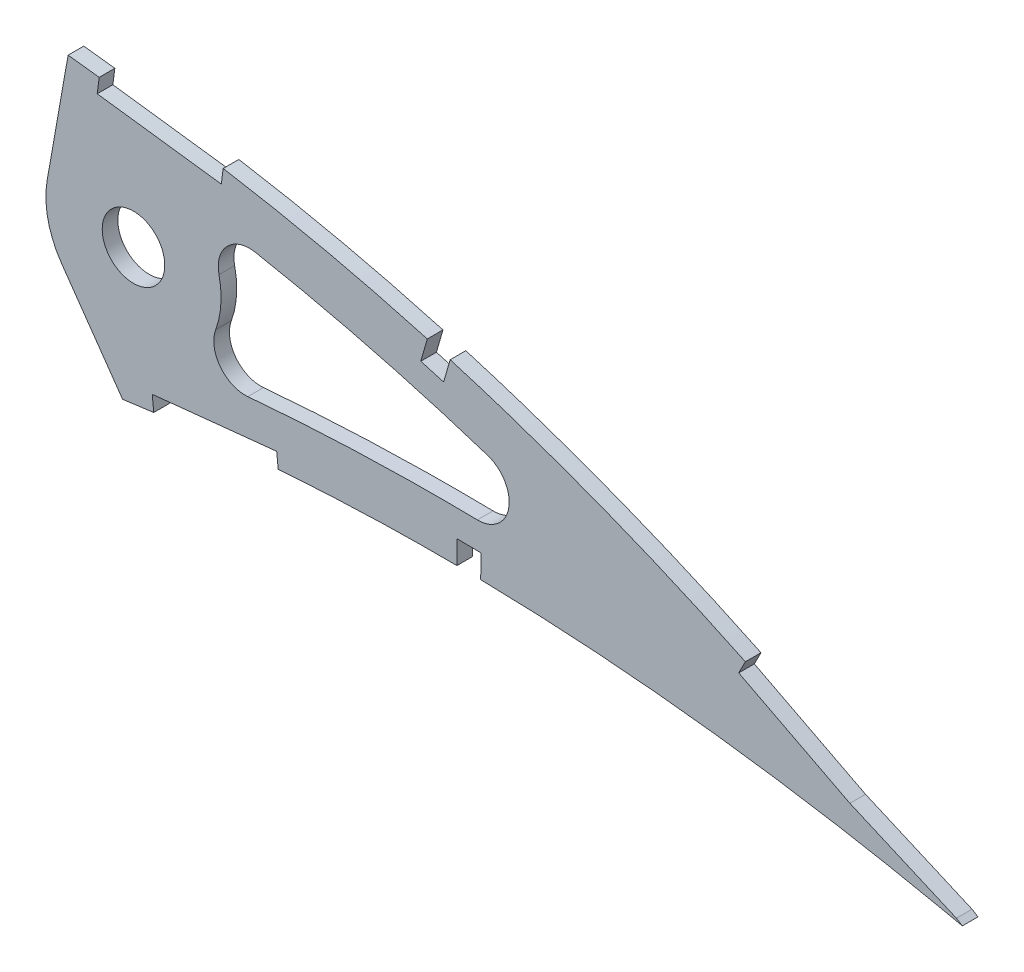
from build123d import *

# Parameters (mm, degrees)
BOSS_EXTRUDE1_DEPTH = 3.175
CUT_EXTRUDE2_DEPTH  = 547.283591975
CUT_EXTRUDE3_DEPTH  = 7.62
FILLET1_R           = 6.35


with BuildPart() as part:
    # Sketch1 → Boss-Extrude1 (new body)
    with BuildSketch(Plane.XY):
        with BuildLine():
            Line((537.523793479, 0.838014197), (542.021387547, -1.940403701))
            Line((542.021387547, -1.940403701), (536.853382121, -0.838014197))
            add(Edge.make_bspline(
                [(0, 0), (0.138034208, -0.651613517), (0.414737006, -1.957835249), (1.166502385, -3.838253351), (2.160676214, -5.645879833), (3.41812392, -7.375913216), (4.930484677, -9.027880677), (6.694418268, -10.603500449), (8.708194811, -12.101925363), (10.969178631, -13.522473474), (13.474085311, -14.866652746), (16.220099339, -16.13362747), (19.204716902, -17.323001708), (22.424686182, -18.433185568), (25.876070677, -19.465869836), (29.555588987, -20.418537931), (33.459057132, -21.292521383), (37.582720715, -22.085589251), (41.922086221, -22.79854726), (46.47264566, -23.430996401), (51.229728203, -23.983332235), (56.188666796, -24.454395789), (61.344556547, -24.845200266), (66.692258515, -25.156004942), (72.226581781, -25.387795347), (77.942225046, -25.539690341), (83.833590491, -25.614057961), (89.895353971, -25.612014663), (96.121585635, -25.533013935), (102.506966812, -25.38142005), (109.045370018, -25.156272786), (115.730892393, -24.860296695), (122.557503504, -24.496470357), (129.519080627, -24.066027182), (136.609497338, -23.570874854), (143.822597201, -23.014984243), (151.151827785, -22.399741923), (158.590797026, -21.728733991), (166.132919157, -21.00531964), (173.771677913, -20.231788358), (181.500330731, -19.411778876), (189.311993833, -18.547948429), (197.200021897, -17.644905548), (205.157209236, -16.704284062), (213.176827191, -15.731454523), (221.251331322, -14.728275603), (229.373969711, -13.698611248), (237.537436822, -12.64730964), (245.734090261, -11.574250863), (253.957036061, -10.487080023), (262.198344279, -9.384901746), (270.450841426, -8.273384527), (278.706888239, -7.155983301), (286.958443262, -6.033041983), (295.198253093, -4.90921431), (303.41867388, -3.787585418), (311.611653564, -2.668257785), (319.769779667, -1.556794947), (327.884837197, -0.453060986), (335.949343265, 0.640706274), (343.955569803, 1.721242065), (351.895963319, 2.787182649), (359.762332786, 3.837853602), (367.54676401, 4.873649521), (375.124885566, 5.86313137), (382.476895799, 6.858989414), (389.627569535, 7.675372288), (396.689208318, 8.372184453), (403.669147402, 8.943474279), (410.559005462, 9.397460881), (417.35088821, 9.737388222), (424.036701118, 9.968002084), (430.607999049, 10.096143944), (437.056574293, 10.125065717), (443.373624814, 10.063990775), (449.550934642, 9.917842246), (455.579882304, 9.693180036), (461.452056886, 9.397583865), (467.159117519, 9.039111896), (472.692496198, 8.623051856), (478.044482343, 8.159116909), (483.20681867, 7.654098497), (488.171578303, 7.113766584), (492.931516981, 6.549443229), (497.479015862, 5.964843963), (501.807234808, 5.369575836), (505.909206574, 4.769671288), (509.778434754, 4.172789296), (513.408840214, 3.584624041), (516.794558715, 3.012982056), (519.930286636, 2.463204222), (522.810582624, 1.940659579), (525.431450895, 1.451941159), (527.787715212, 0.999476696), (529.876224241, 0.590722876), (531.693094624, 0.227483345), (533.235662954, -0.085124276), (534.501235327, -0.345866251), (535.487889575, -0.550462297), (536.193676878, -0.699239352), (536.617833842, -0.78776929), (536.806292235, -0.827969433), (536.853382121, -0.838014197)],
                knots=[0, 0, 0, 0, 0.003638255, 0.007293231, 0.011028136, 0.014901081, 0.018963272, 0.023258475, 0.027820626, 0.032679082, 0.03785316, 0.043361875, 0.049214679, 0.055422346, 0.061988786, 0.068918036, 0.076211157, 0.083868392, 0.091887411, 0.100265912, 0.108999867, 0.118084529, 0.127514843, 0.13728527, 0.147387917, 0.157816481, 0.168563473, 0.179619128, 0.190977373, 0.202626974, 0.214560478, 0.226767249, 0.239236417, 0.251959004, 0.264923894, 0.278119703, 0.291536035, 0.30516028, 0.318980685, 0.332985499, 0.34716279, 0.361498603, 0.375980747, 0.390597192, 0.405332593, 0.420174823, 0.435109533, 0.450124276, 0.465203068, 0.480333154, 0.495500583, 0.510689775, 0.525887334, 0.541078314, 0.556247233, 0.571381784, 0.58646604, 0.601484516, 0.616424329, 0.631269422, 0.646006524, 0.660620684, 0.675098187, 0.689422858, 0.703581825, 0.716907563, 0.730009274, 0.742952128, 0.755725558, 0.768319952, 0.780724337, 0.792926529, 0.804916041, 0.816679084, 0.828203524, 0.8394749, 0.850481359, 0.861207697, 0.871639326, 0.881763414, 0.891563605, 0.901027364, 0.910138977, 0.918883976, 0.927249278, 0.935221104, 0.942784739, 0.949928188, 0.956638464, 0.962904203, 0.968712288, 0.974054485, 0.978918432, 0.983297218, 0.987180246, 0.990560674, 0.993433357, 0.995790626, 0.997629587, 0.998945816, 0.999736592, 1, 1, 1, 1], degree=3))
            add(Edge.make_bspline(
                [(537.523793479, 0.838014197), (537.482615732, 0.863452017), (537.318064528, 0.96510459), (536.947300697, 1.192526083), (536.329901806, 1.57130801), (535.46559731, 2.098819483), (534.355058257, 2.773659514), (532.997726083, 3.59110281), (531.394448119, 4.54849361), (529.545612388, 5.641303796), (527.451408281, 6.86441657), (525.112633224, 8.21287684), (522.529490774, 9.679050377), (519.702981637, 11.256946414), (516.634075426, 12.939060426), (513.323352771, 14.717795209), (509.771999152, 16.584102922), (505.981377851, 18.529956506), (501.952179943, 20.544610393), (497.686305121, 22.619680198), (493.18517462, 24.744819484), (488.450324771, 26.908690342), (483.484475652, 29.10247161), (478.289000223, 31.312524792), (472.866859293, 33.529274563), (467.220361199, 35.74010496), (461.352849174, 37.93494721), (455.266586971, 40.099582697), (448.966124199, 42.224551766), (442.454517235, 44.29604992), (435.736422737, 46.30282705), (428.815744024, 48.23187216), (421.698250245, 50.073291993), (414.388455333, 51.81367658), (406.892554856, 53.441376499), (399.216507212, 54.946591973), (391.366750067, 56.314295462), (383.365035839, 57.543420661), (375.340110277, 58.565844722), (367.331695381, 59.568608396), (359.33520696, 60.510613179), (351.240984711, 61.412713021), (343.056815752, 62.269828969), (334.790818119, 63.079280807), (326.451359929, 63.837575043), (318.047107413, 64.542487925), (309.586192901, 65.190025104), (301.077537968, 65.77918901), (292.529554555, 66.304800113), (283.951347283, 66.766463817), (275.351624178, 67.160960307), (266.739334656, 67.485571411), (258.123623749, 67.738337522), (249.513434854, 67.916837067), (240.918090619, 68.019947775), (232.346531537, 68.044852228), (223.808075907, 67.9911049), (215.311664889, 67.856860342), (206.866626287, 67.640280799), (198.481913458, 67.340962045), (190.166593165, 66.959033914), (181.929769837, 66.491298026), (173.780378961, 65.940735117), (165.727495548, 65.305032423), (157.779967433, 64.584020875), (149.9461237, 63.780705916), (142.234686098, 62.892902653), (134.653918954, 61.923137139), (127.2121141, 60.873310758), (119.917621446, 59.742851607), (112.778255016, 58.535025019), (105.801720226, 57.251066746), (98.995398233, 55.894740955), (92.366699314, 54.466401509), (85.922640298, 52.970332999), (79.66991824, 51.40914198), (73.615254674, 49.785686485), (67.764787279, 48.103862095), (62.124432152, 46.36748437), (56.700764602, 44.578461264), (51.497883725, 42.743575913), (46.522180738, 40.864130885), (41.777467174, 38.945916209), (37.269303476, 36.991551041), (33.001057421, 35.006993284), (28.977559684, 32.994502304), (25.201677836, 30.959716413), (21.67720255, 28.905755725), (18.407526536, 26.836435266), (15.394024003, 24.75700399), (12.640849753, 22.668767086), (10.148949542, 20.577001449), (7.919900318, 18.484892293), (5.956888292, 16.393880779), (4.259842806, 14.307649188), (2.830987907, 12.227849748), (1.670571486, 10.156450442), (0.781218216, 8.094955971), (0.162046196, 6.044525665), (-0.176884415, 4.008185904), (-0.261246296, 1.984304191), (-0.086951983, 0.66044643), (0, 0)],
                knots=[0, 0, 0, 0, 0.00025409, 0.001015373, 0.002283359, 0.004056577, 0.006330982, 0.009105274, 0.012374489, 0.016134023, 0.02037966, 0.025105976, 0.030306237, 0.035972206, 0.042099522, 0.048678064, 0.055701664, 0.063160184, 0.071045824, 0.079349827, 0.08806291, 0.097175756, 0.106678112, 0.116561573, 0.126814276, 0.137428301, 0.148393618, 0.15969976, 0.171338126, 0.183297699, 0.195569604, 0.208143555, 0.221011593, 0.234161831, 0.24758745, 0.261276822, 0.27522271, 0.289414144, 0.3037712, 0.317689227, 0.331784111, 0.346039677, 0.360443869, 0.37498272, 0.389640454, 0.404403317, 0.419256601, 0.434186749, 0.449177265, 0.464214782, 0.479284009, 0.49436974, 0.509457833, 0.524532346, 0.53957932, 0.554582984, 0.569529546, 0.584403417, 0.599190992, 0.613876838, 0.628447475, 0.642888675, 0.657186054, 0.671325546, 0.685294014, 0.699078147, 0.712665095, 0.726042645, 0.739197713, 0.752117586, 0.764792042, 0.777208152, 0.789355685, 0.80122396, 0.812803686, 0.824082909, 0.835054602, 0.845709571, 0.856037853, 0.866033834, 0.875688843, 0.884997719, 0.893953426, 0.902552897, 0.910789386, 0.918660734, 0.926166253, 0.933302626, 0.94007122, 0.94647478, 0.952517526, 0.958204819, 0.963546652, 0.9685566, 0.973249913, 0.977651041, 0.981787043, 0.985694226, 0.989415109, 0.993001157, 0.996508416, 1, 1, 1, 1], degree=3))
        make_face()
    extrude(amount=BOSS_EXTRUDE1_DEPTH)

    # Sketch4 → Cut-Extrude2 (cut, through all)
    with BuildSketch(Plane(origin=(0, 0, 0), x_dir=(-1, 0, 0), z_dir=(0, 0, -1))):
        with BuildLine():
            Line((-358.759404849, 50.341973877), (-356.286959494, 36.320039485))
            ThreePointArc((-356.286959494, 36.320039485), (-356.084499611, 34.782203992), (-356.016841343, 33.232574886))
            ThreePointArc((-356.016841343, 33.232574886), (-356.839753959, 27.886025771), (-359.232317995, 23.034385848))
            Line((-359.232317995, 23.034385848), (-365.009526555, 14.783676959))
            add(Edge.make_bspline(
                [(-10.021942702, 1.718500729), (-10.03611103, 1.652941612), (-10.066454514, 1.514352457), (-10.115705893, 1.29794685), (-10.166915987, 1.09309351), (-10.193753582, 1.00087628), (-10.226738578, 0.900819463), (-10.31965399, 0.662508567), (-10.570520523, 0.145785763), (-10.915684268, -0.419891652), (-11.740399951, -1.46896166), (-13.263463708, -2.893704584), (-16.570451294, -5.135479325), (-21.864088346, -7.604586117), (-29.07378135, -9.894329499), (-36.746223283, -11.651982176), (-44.683392891, -12.978776186), (-52.784411112, -13.962638335), (-63.727270251, -14.894469584), (-77.583039824, -15.471934019), (-94.347594846, -15.477173303), (-111.186626853, -14.956912237), (-133.693808871, -13.713140806), (-161.882487764, -11.342237144), (-195.735721837, -7.668543133), (-229.609236072, -3.472001762), (-263.496648353, 1.020794303), (-297.414197691, 5.645749066), (-325.695601302, 9.509973366), (-345.51326685, 12.183980853), (-356.726946334, 13.682803734), (-362.282196392, 14.423395867), (-365.009526555, 14.783676959)],
                knots=[0.000796287, 0.000796287, 0.000796287, 0.000796287, 0.001284179, 0.001772072, 0.002747857, 0.003723642, 0.004699427, 0.006650996, 0.008602566, 0.012505706, 0.016408845, 0.024215124, 0.032021403, 0.047633961, 0.063246519, 0.078859077, 0.094471635, 0.110084193, 0.125696751, 0.156921867, 0.188146983, 0.219372099, 0.250597215, 0.313047447, 0.375497679, 0.437947911, 0.500398144, 0.562848376, 0.625298608, 0.656523724, 0.672136282, 0.687148678, 0.687148678, 0.687148678, 0.687148678], degree=3))
            add(Edge.make_bspline(
                [(-358.75940485, 50.341973877), (-356.380266699, 50.616298933), (-348.128970055, 51.540224757), (-328.146966099, 53.580781247), (-298.748975119, 55.92382749), (-263.431515106, 57.619554714), (-228.111858641, 58.084439581), (-192.8505907, 57.171044409), (-157.735646623, 54.670892629), (-128.708526782, 51.03645203), (-105.745932423, 46.986985199), (-88.709726391, 43.306028904), (-71.929938282, 38.88419363), (-58.260998809, 34.473373881), (-47.630461825, 30.411454977), (-39.859630358, 27.063046923), (-32.367414081, 23.373301112), (-25.279374363, 19.292839587), (-18.817927144, 14.778105697), (-14.319044671, 10.653419674), (-11.718740883, 7.337797858), (-10.660553909, 5.426773981), (-10.238198662, 4.264531094), (-10.088376275, 3.696752589), (-10.010100537, 3.294970231), (-9.955251683, 2.849622867), (-9.943193718, 2.572345022), (-9.945266136, 2.451754417), (-9.949314756, 2.371337668), (-9.968775679, 2.15977884), (-9.994917102, 1.933855932), (-10.013150874, 1.787473861), (-10.021942702, 1.718500729)],
                knots=[0.330806535, 0.330806535, 0.330806535, 0.330806535, 0.343487225, 0.374713336, 0.437165559, 0.499617781, 0.562070004, 0.624522227, 0.686974449, 0.749426672, 0.780652783, 0.811878895, 0.843105006, 0.874331117, 0.889944173, 0.905557229, 0.921170284, 0.93678334, 0.952396396, 0.968009451, 0.975815979, 0.983622507, 0.987525771, 0.989477403, 0.991429035, 0.993380667, 0.995332299, 0.996308115, 0.997283931, 0.998259747, 0.998747655, 0.999235563, 0.999235563, 0.999235563, 0.999235563], degree=3))
        make_face()
        with BuildLine():
            ThreePointArc((-367.446841343, 33.232574886), (-373.796841343, 39.582574886), (-380.146841343, 33.232574886))
            ThreePointArc((-380.146841343, 33.232574886), (-373.796841343, 26.882574886), (-367.446841343, 33.232574886))
        make_face()
        with BuildLine():
            Line((-360.526726967, 60.364955673), (-358.759404849, 50.341973877))
            add(Edge.make_bspline(
                [(-358.75940485, 50.341973877), (-356.380266699, 50.616298933), (-348.128970055, 51.540224757), (-328.146966099, 53.580781247), (-298.748975119, 55.92382749), (-263.431515106, 57.619554714), (-228.111858641, 58.084439581), (-192.8505907, 57.171044409), (-157.735646623, 54.670892629), (-128.708526782, 51.03645203), (-105.745932423, 46.986985199), (-88.709726391, 43.306028904), (-71.929938282, 38.88419363), (-58.260998809, 34.473373881), (-47.630461825, 30.411454977), (-39.859630358, 27.063046923), (-32.367414081, 23.373301112), (-25.279374363, 19.292839587), (-18.817927144, 14.778105697), (-14.319044671, 10.653419674), (-11.718740883, 7.337797858), (-10.660553909, 5.426773981), (-10.238198662, 4.264531094), (-10.088376275, 3.696752589), (-10.010100537, 3.294970231), (-9.955251683, 2.849622867), (-9.943193718, 2.572345022), (-9.945266136, 2.451754417), (-9.949314756, 2.371337668), (-9.968775679, 2.15977884), (-9.994917102, 1.933855932), (-10.013150874, 1.787473861), (-10.021942702, 1.718500729)],
                knots=[0.330806535, 0.330806535, 0.330806535, 0.330806535, 0.343487225, 0.374713336, 0.437165559, 0.499617781, 0.562070004, 0.624522227, 0.686974449, 0.749426672, 0.780652783, 0.811878895, 0.843105006, 0.874331117, 0.889944173, 0.905557229, 0.921170284, 0.93678334, 0.952396396, 0.968009451, 0.975815979, 0.983622507, 0.987525771, 0.989477403, 0.991429035, 0.993380667, 0.995332299, 0.996308115, 0.997283931, 0.998259747, 0.998747655, 0.999235563, 0.999235563, 0.999235563, 0.999235563], degree=3))
            add(Edge.make_bspline(
                [(-10.021942702, 1.718500729), (-10.03611103, 1.652941612), (-10.066454514, 1.514352457), (-10.115705893, 1.29794685), (-10.166915987, 1.09309351), (-10.193753582, 1.00087628), (-10.226738578, 0.900819463), (-10.31965399, 0.662508567), (-10.570520523, 0.145785763), (-10.915684268, -0.419891652), (-11.740399951, -1.46896166), (-13.263463708, -2.893704584), (-16.570451294, -5.135479325), (-21.864088346, -7.604586117), (-29.07378135, -9.894329499), (-36.746223283, -11.651982176), (-44.683392891, -12.978776186), (-52.784411112, -13.962638335), (-63.727270251, -14.894469584), (-77.583039824, -15.471934019), (-94.347594846, -15.477173303), (-111.186626853, -14.956912237), (-133.693808871, -13.713140806), (-161.882487764, -11.342237144), (-195.735721837, -7.668543133), (-229.609236072, -3.472001762), (-263.496648353, 1.020794303), (-297.414197691, 5.645749066), (-325.695601302, 9.509973366), (-345.51326685, 12.183980853), (-356.726946334, 13.682803734), (-362.282196392, 14.423395867), (-365.009526555, 14.783676959)],
                knots=[0.000796287, 0.000796287, 0.000796287, 0.000796287, 0.001284179, 0.001772072, 0.002747857, 0.003723642, 0.004699427, 0.006650996, 0.008602566, 0.012505706, 0.016408845, 0.024215124, 0.032021403, 0.047633961, 0.063246519, 0.078859077, 0.094471635, 0.110084193, 0.125696751, 0.156921867, 0.188146983, 0.219372099, 0.250597215, 0.313047447, 0.375497679, 0.437947911, 0.500398144, 0.562848376, 0.625298608, 0.656523724, 0.672136282, 0.687148678, 0.687148678, 0.687148678, 0.687148678], degree=3))
            Line((-365.009526555, 14.783676959), (-371.579512679, 5.400764372))
            add(Edge.make_bspline(
                [(0, 0), (-0.138034208, -0.651613517), (-0.414737006, -1.957835249), (-1.166502385, -3.838253351), (-2.160676214, -5.645879833), (-3.41812392, -7.375913216), (-4.930484677, -9.027880677), (-6.694418268, -10.603500449), (-8.708194811, -12.101925363), (-10.969178631, -13.522473474), (-13.474085311, -14.866652746), (-16.220099339, -16.13362747), (-19.204716902, -17.323001708), (-22.424686182, -18.433185568), (-25.876070677, -19.465869836), (-29.555588987, -20.418537931), (-33.459057132, -21.292521383), (-37.582720715, -22.085589251), (-41.922086221, -22.79854726), (-46.47264566, -23.430996401), (-51.229728203, -23.983332235), (-56.188666796, -24.454395789), (-61.344556547, -24.845200266), (-66.692258515, -25.156004942), (-72.226581781, -25.387795347), (-77.942225046, -25.539690341), (-83.833590491, -25.614057961), (-89.895353971, -25.612014663), (-96.121585635, -25.533013935), (-102.506966812, -25.38142005), (-109.045370018, -25.156272786), (-115.730892393, -24.860296695), (-122.557503504, -24.496470357), (-129.519080627, -24.066027182), (-136.609497338, -23.570874854), (-143.822597201, -23.014984243), (-151.151827785, -22.399741923), (-158.590797026, -21.728733991), (-166.132919157, -21.00531964), (-173.771677913, -20.231788358), (-181.500330731, -19.411778876), (-189.311993833, -18.547948429), (-197.200021897, -17.644905548), (-205.157209236, -16.704284062), (-213.176827191, -15.731454523), (-221.251331322, -14.728275603), (-229.373969711, -13.698611248), (-237.537436822, -12.64730964), (-245.734090261, -11.574250863), (-253.957036061, -10.487080023), (-262.198344279, -9.384901746), (-270.450841426, -8.273384527), (-278.706888239, -7.155983301), (-286.958443262, -6.033041983), (-295.198253093, -4.90921431), (-303.41867388, -3.787585418), (-311.611653564, -2.668257785), (-319.769779667, -1.556794947), (-327.884837197, -0.453060986), (-335.949343265, 0.640706274), (-343.955569803, 1.721242065), (-351.895963319, 2.787182649), (-359.762332786, 3.837853602), (-366.315041689, 4.709756628), (-370.245412424, 5.225282692), (-371.579512679, 5.400764372)],
                knots=[0, 0, 0, 0, 0.003638255, 0.007293231, 0.011028136, 0.014901081, 0.018963272, 0.023258475, 0.027820626, 0.032679082, 0.03785316, 0.043361875, 0.049214679, 0.055422346, 0.061988786, 0.068918036, 0.076211157, 0.083868392, 0.091887411, 0.100265912, 0.108999867, 0.118084529, 0.127514843, 0.13728527, 0.147387917, 0.157816481, 0.168563473, 0.179619128, 0.190977373, 0.202626974, 0.214560478, 0.226767249, 0.239236417, 0.251959004, 0.264923894, 0.278119703, 0.291536035, 0.30516028, 0.318980685, 0.332985499, 0.34716279, 0.361498603, 0.375980747, 0.390597192, 0.405332593, 0.420174823, 0.435109533, 0.450124276, 0.465203068, 0.480333154, 0.495500583, 0.510689775, 0.525887334, 0.541078314, 0.556247233, 0.571381784, 0.58646604, 0.601484516, 0.616424329, 0.631269422, 0.646006524, 0.660620684, 0.675098187, 0.689422858, 0.696784129, 0.696784129, 0.696784129, 0.696784129], degree=3))
            add(Edge.make_bspline(
                [(-360.526726967, 60.364955673), (-360.13939216, 60.409720829), (-357.05430612, 60.764819232), (-351.240984711, 61.412713021), (-343.056815752, 62.269828969), (-334.790818119, 63.079280807), (-326.451359929, 63.837575043), (-318.047107413, 64.542487925), (-309.586192901, 65.190025104), (-301.077537968, 65.77918901), (-292.529554555, 66.304800113), (-283.951347283, 66.766463817), (-275.351624178, 67.160960307), (-266.739334656, 67.485571411), (-258.123623749, 67.738337522), (-249.513434854, 67.916837067), (-240.918090619, 68.019947775), (-232.346531537, 68.044852228), (-223.808075907, 67.9911049), (-215.311664889, 67.856860342), (-206.866626287, 67.640280799), (-198.481913458, 67.340962045), (-190.166593165, 66.959033914), (-181.929769837, 66.491298026), (-173.780378961, 65.940735117), (-165.727495548, 65.305032423), (-157.779967433, 64.584020875), (-149.9461237, 63.780705916), (-142.234686098, 62.892902653), (-134.653918954, 61.923137139), (-127.2121141, 60.873310758), (-119.917621446, 59.742851607), (-112.778255016, 58.535025019), (-105.801720226, 57.251066746), (-98.995398233, 55.894740955), (-92.366699314, 54.466401509), (-85.922640298, 52.970332999), (-79.66991824, 51.40914198), (-73.615254674, 49.785686485), (-67.764787279, 48.103862095), (-62.124432152, 46.36748437), (-56.700764602, 44.578461264), (-51.497883725, 42.743575913), (-46.522180738, 40.864130885), (-41.777467174, 38.945916209), (-37.269303476, 36.991551041), (-33.001057421, 35.006993284), (-28.977559684, 32.994502304), (-25.201677836, 30.959716413), (-21.67720255, 28.905755725), (-18.407526536, 26.836435266), (-15.394024003, 24.75700399), (-12.640849753, 22.668767086), (-10.148949542, 20.577001449), (-7.919900318, 18.484892293), (-5.956888292, 16.393880779), (-4.259842806, 14.307649188), (-2.830987907, 12.227849748), (-1.670571486, 10.156450442), (-0.781218216, 8.094955971), (-0.162046196, 6.044525665), (0.176884415, 4.008185904), (0.261246296, 1.984304191), (0.086951983, 0.66044643), (0, 0)],
                knots=[0.329737216, 0.329737216, 0.329737216, 0.329737216, 0.331784111, 0.346039677, 0.360443869, 0.37498272, 0.389640454, 0.404403317, 0.419256601, 0.434186749, 0.449177265, 0.464214782, 0.479284009, 0.49436974, 0.509457833, 0.524532346, 0.53957932, 0.554582984, 0.569529546, 0.584403417, 0.599190992, 0.613876838, 0.628447475, 0.642888675, 0.657186054, 0.671325546, 0.685294014, 0.699078147, 0.712665095, 0.726042645, 0.739197713, 0.752117586, 0.764792042, 0.777208152, 0.789355685, 0.80122396, 0.812803686, 0.824082909, 0.835054602, 0.845709571, 0.856037853, 0.866033834, 0.875688843, 0.884997719, 0.893953426, 0.902552897, 0.910789386, 0.918660734, 0.926166253, 0.933302626, 0.94007122, 0.94647478, 0.952517526, 0.958204819, 0.963546652, 0.9685566, 0.973249913, 0.977651041, 0.981787043, 0.985694226, 0.989415109, 0.993001157, 0.996508416, 1, 1, 1, 1], degree=3))
        make_face()
        with BuildLine():
            ThreePointArc((-391.576841343, 33.232574886), (-389.864229199, 40.846210514), (-385.056318566, 46.99311894))
            add(Edge.make_bspline(
                [(-483.945277453, 17.782093716), (-479.37869056, 19.828738879), (-464.101486778, 26.335024231), (-442.96941175, 33.791006158), (-420.638573326, 39.978517334), (-406.51494969, 43.196118714), (-395.153069217, 45.36374072), (-388.916755362, 46.409790636), (-385.561376483, 46.917807663), (-385.056318566, 46.99311894)],
                knots=[0.097967511, 0.097967511, 0.097967511, 0.097967511, 0.124904445, 0.187356668, 0.218582779, 0.249808891, 0.265421946, 0.281035002, 0.283801476, 0.283801476, 0.283801476, 0.283801476], degree=3))
            add(Edge.make_bspline(
                [(-380.708136876, 16.850804711), (-381.278127665, 16.922778664), (-383.305182899, 17.174627253), (-386.786120963, 17.575507047), (-392.58278563, 18.187634312), (-402.773771505, 19.115011682), (-417.34679611, 20.003093808), (-440.709649319, 20.51010277), (-462.937810441, 19.701213451), (-479.254342954, 18.263445051), (-483.945277453, 17.782093716)],
                knots=[0.715911003, 0.715911003, 0.715911003, 0.715911003, 0.718973956, 0.726780235, 0.734586514, 0.750199072, 0.781424188, 0.812649304, 0.875099536, 0.900362401, 0.900362401, 0.900362401, 0.900362401], degree=3))
            ThreePointArc((-380.708136876, 16.850804711), (-388.612563306, 23.402886045), (-391.576841343, 33.232574886))
        make_face()
    extrude(amount=-CUT_EXTRUDE2_DEPTH, mode=Mode.SUBTRACT)

    # Sketch5 → Cut-Extrude3 (cut)
    with BuildSketch(Plane.XY.offset(3.175)):
        Polygon((392.026401536, 56.390657128), (366.842305925, 59.674265489), (366.43185488, 56.526253538), (391.615950491, 53.242645177), align=None)
        Polygon((402.855659038, 11.892356637), (377.596720263, 9.282624876), (377.922936734, 6.12525753), (403.181875508, 8.734989291), align=None)
        Polygon((438.08047255, 45.648806451), (433.445232123, 46.987621362), (432.106417212, 42.352380934), (436.741657639, 41.013566024), align=None)
        Polygon((444.326796582, 14.772026559), (439.502338831, 14.836452782), (439.437912607, 10.011995031), (444.262370359, 9.947568807), align=None)
        Polygon((520.560283096, 11.064042442), (498.077277501, 22.652570205), (496.62265431, 19.830442838), (519.199673242, 8.193457312), (542.497437426, -1.924455793), (543.762176564, 0.98776473), align=None)
    extrude(amount=-CUT_EXTRUDE3_DEPTH, mode=Mode.SUBTRACT)


with BuildPart() as body_2:
    # of the pieces the cut leaves, the one that is kept (cut_extrude3_keep)
    add(part.part.solids().sort_by_distance((540.807616413, -1.190588713, 0))[0])

    # Fillet1
    fillet1_edges = [body_2.edges().sort_by_distance(p)[0] for p in [
        (483.945277453, 17.782093716, 1.5875),
        (380.708136876, 16.850804711, 1.5875),
        (385.056318566, 46.99311894, 1.5875),
    ]]
    fillet(fillet1_edges, radius=FILLET1_R)


solid = body_2.part
